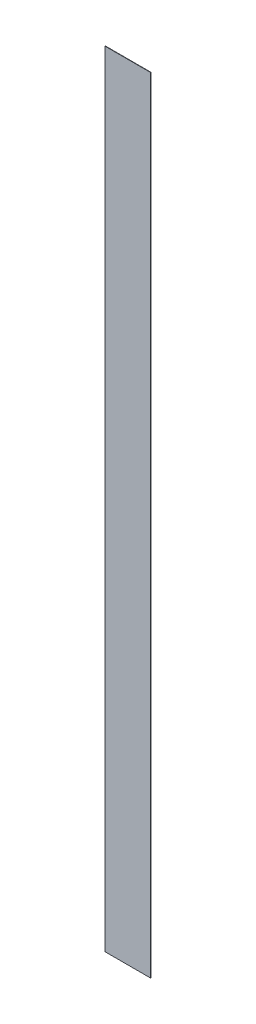
from build123d import *

# Parameters (mm, degrees)
SKETCH1_W           = 17.351797945
SKETCH1_H           = 300
BOSS_EXTRUDE1_DEPTH = 0.14


with BuildPart() as part:
    # Sketch1 → Boss-Extrude1 (new body)
    with BuildSketch(Plane.XY):
        with Locations((-36.549363647, 187.002015646)):
            Rectangle(SKETCH1_W, SKETCH1_H)
    extrude(amount=BOSS_EXTRUDE1_DEPTH)


solid = part.part
